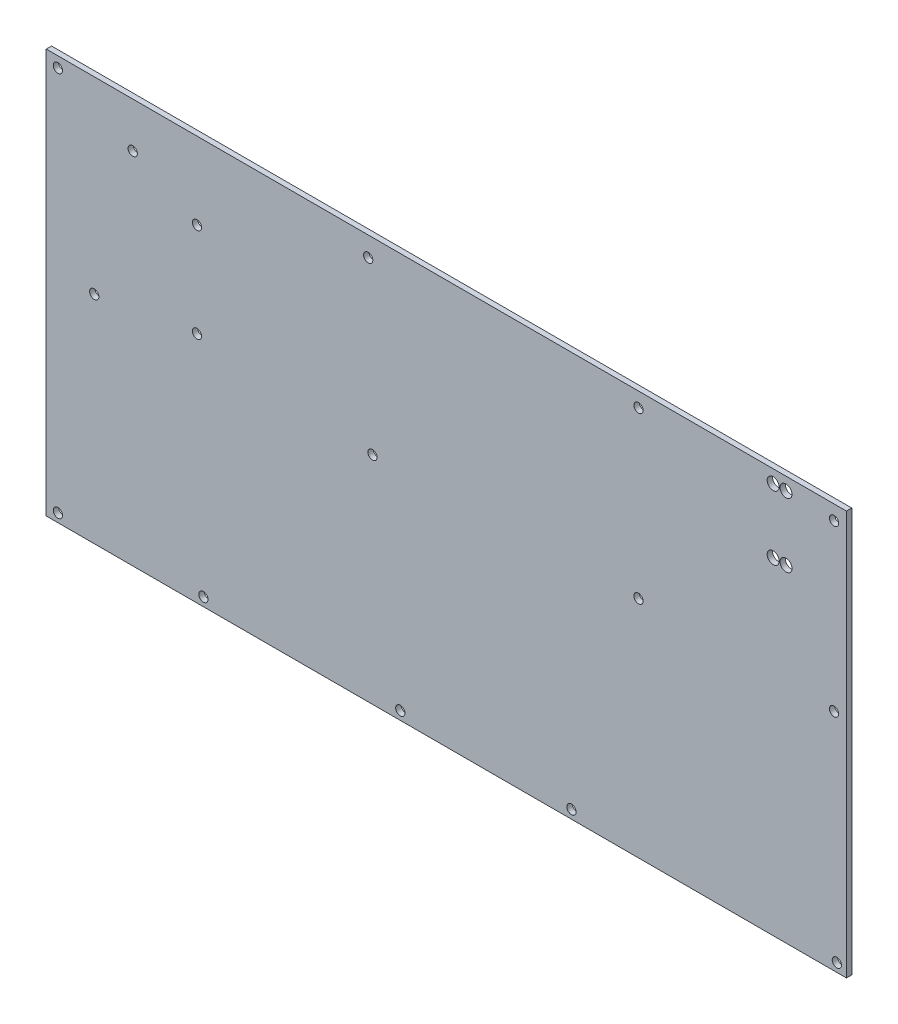
from build123d import *

# Parameters (mm, degrees)
BOSS_EXTRUDE1_START = 6
SKETCH1_W           = 237.4392
SKETCH1_H           = 119.9896
SKETCH1_R           = 1.3716
SKETCH1_R_2         = 1.778
BOSS_EXTRUDE1_DEPTH = 1.5748


with BuildPart() as part:
    # Sketch1 → Boss-Extrude1 (new body)
    with BuildSketch(Plane.XY.offset(BOSS_EXTRUDE1_START)):
        with Locations((78.797443137, 19.612784314)):
            Rectangle(SKETCH1_W, SKETCH1_H)
        with Locations((193.834043137, 75.289584314)):
            Circle(SKETCH1_R, mode=Mode.SUBTRACT)
        with Locations((135.815363137, 75.289584314)):
            Circle(SKETCH1_R, mode=Mode.SUBTRACT)
        with Locations((193.834043137, 26.292984314)):
            Circle(SKETCH1_R, mode=Mode.SUBTRACT)
        with Locations((135.820443137, 26.292984314)):
            Circle(SKETCH1_R, mode=Mode.SUBTRACT)
        with Locations((194.672243137, -37.842015686)):
            Circle(SKETCH1_R, mode=Mode.SUBTRACT)
        with Locations((115.932243137, -37.842015686)):
            Circle(SKETCH1_R, mode=Mode.SUBTRACT)
        with Locations((55.607243137, 73.790984314)):
            Circle(SKETCH1_R, mode=Mode.SUBTRACT)
        with Locations((56.877243137, 23.752984314)):
            Circle(SKETCH1_R, mode=Mode.SUBTRACT)
        with Locations((65.132243137, -37.842015686)):
            Circle(SKETCH1_R, mode=Mode.SUBTRACT)
        with Locations((4.807243137, 56.772984314)):
            Circle(SKETCH1_R, mode=Mode.SUBTRACT)
        with Locations((4.807243137, 28.832984314)):
            Circle(SKETCH1_R, mode=Mode.SUBTRACT)
        with Locations((6.712243137, -37.842015686)):
            Circle(SKETCH1_R, mode=Mode.SUBTRACT)
        with Locations((-14.271778871, 66.267235766)):
            Circle(SKETCH1_R, mode=Mode.SUBTRACT)
        with Locations((-36.467756863, 76.483384314)):
            Circle(SKETCH1_R, mode=Mode.SUBTRACT)
        with Locations((-25.672756863, 23.752984314)):
            Circle(SKETCH1_R, mode=Mode.SUBTRACT)
        with Locations((-36.467756863, -37.842015686)):
            Circle(SKETCH1_R, mode=Mode.SUBTRACT)
        with Locations((179.584643137, 75.822984314)):
            Circle(SKETCH1_R_2, mode=Mode.SUBTRACT)
        with Locations((175.774643137, 75.797584314)):
            Circle(SKETCH1_R_2, mode=Mode.SUBTRACT)
        with Locations((179.584643137, 56.747584314)):
            Circle(SKETCH1_R_2, mode=Mode.SUBTRACT)
        with Locations((175.774643137, 56.747584314)):
            Circle(SKETCH1_R_2, mode=Mode.SUBTRACT)
    extrude(amount=BOSS_EXTRUDE1_DEPTH)


solid = part.part
